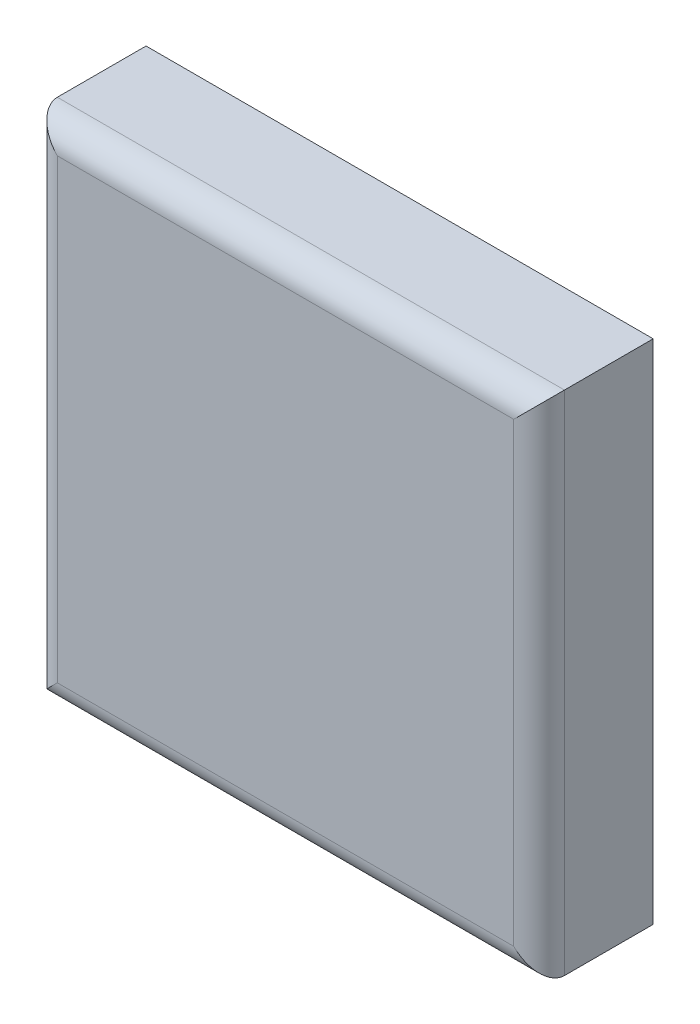
from build123d import *

# Parameters (mm, degrees)
SKETCH1_W           = 45
SKETCH1_H           = 200
BOSS_EXTRUDE1_DEPTH = 100
FILLET1_R           = 10


with BuildPart() as part:
    # Sketch1 → Boss-Extrude1 (new body, symmetric)
    with BuildSketch(Plane(origin=(0, 0, 0), x_dir=(0, 0, -1), z_dir=(1, 0, 0))):
        with Locations((851.406828676, 708.165252796)):
            Rectangle(SKETCH1_W, SKETCH1_H)
    extrude(amount=BOSS_EXTRUDE1_DEPTH, both=True)

    # Fillet1
    fillet1_edges = [part.edges().sort_by_distance(p)[0] for p in [
        (-100, 708.165252796, -828.906828676),
        (0, 608.165252796, -828.906828676),
        (0, 808.165252796, -828.906828676),
        (100, 708.165252796, -828.906828676),
    ]]
    fillet(fillet1_edges, radius=FILLET1_R)


solid = part.part
